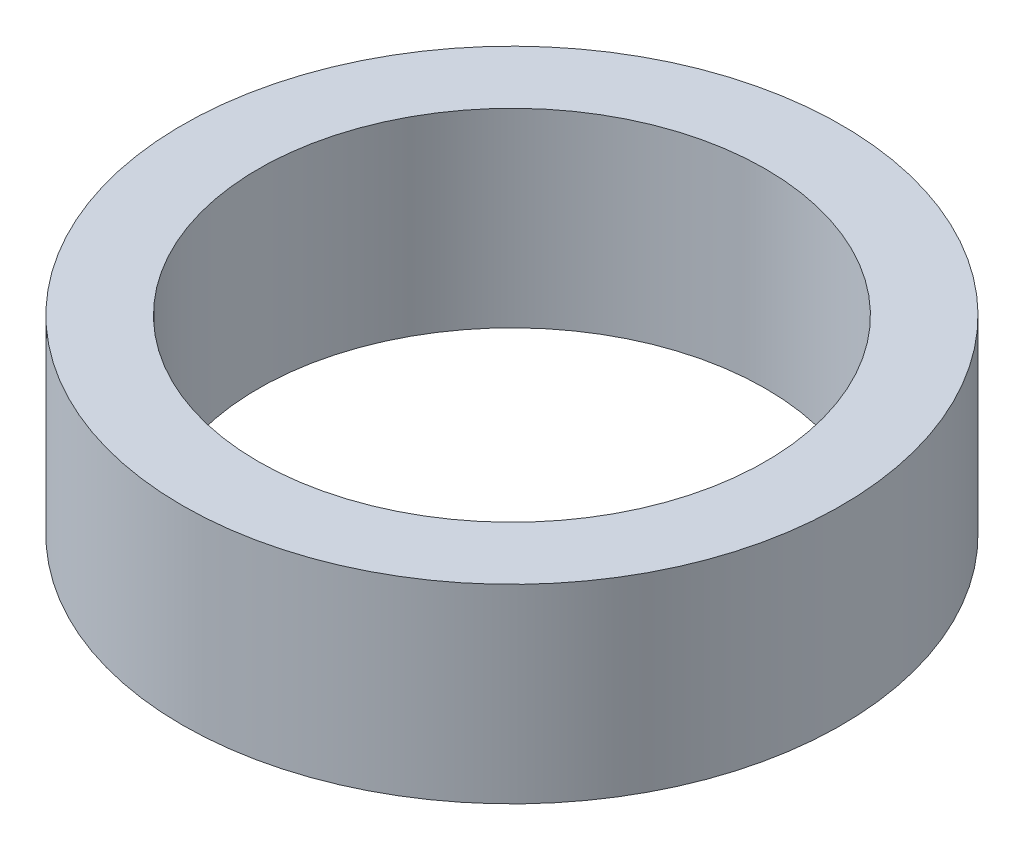
from build123d import *

# Parameters (mm, degrees)
SKETCH1_R           = 2.6
SKETCH1_R_2         = 2
BOSS_EXTRUDE1_DEPTH = 1.5


with BuildPart() as part:
    # Sketch1 → Boss-Extrude1 (new body)
    with BuildSketch(Plane(origin=(0, 0, 0), x_dir=(1, 0, 0), z_dir=(0, 1, 0))):
        Circle(SKETCH1_R)
        Circle(SKETCH1_R_2, mode=Mode.SUBTRACT)
    extrude(amount=BOSS_EXTRUDE1_DEPTH)


solid = part.part
